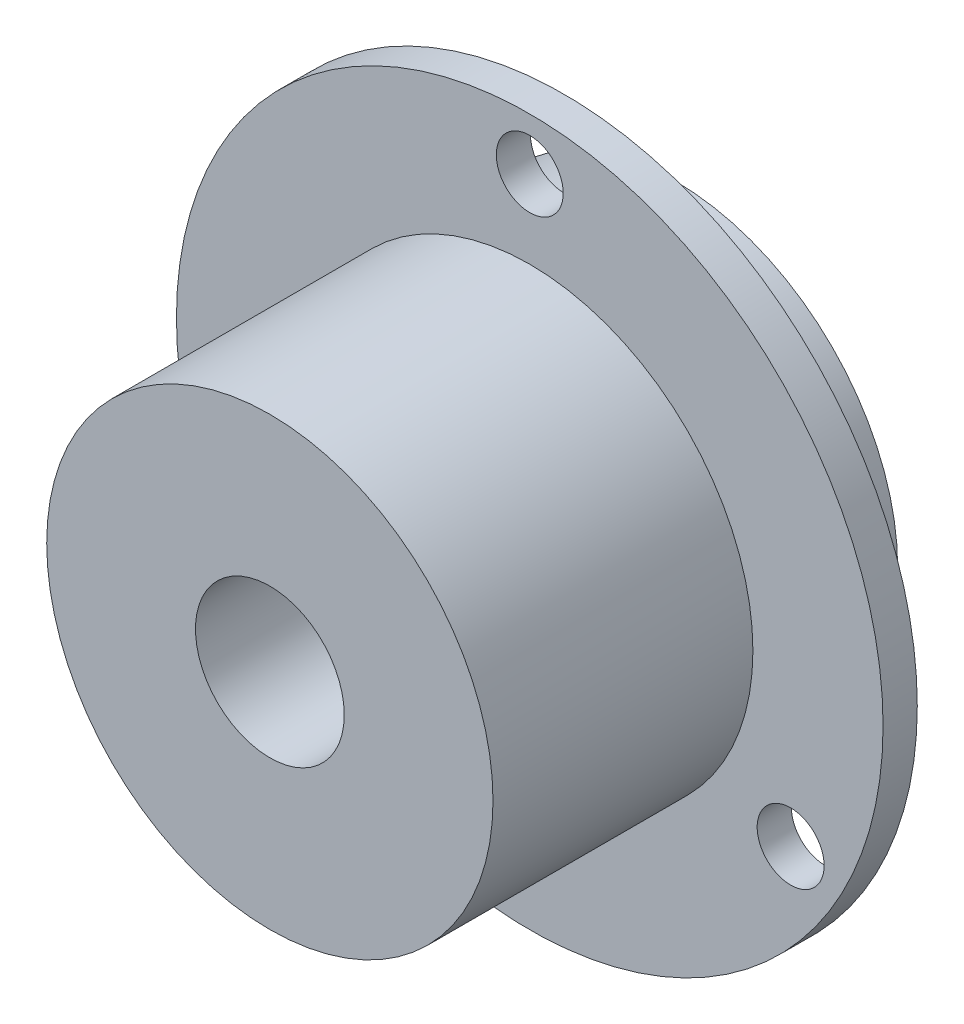
from build123d import *

# Parameters (mm, degrees)
SKETCH3_R          = 2.25
CUT_EXTRUDE1_DEPTH = 5


with BuildPart() as part:
    # Sketch2 → Revolve1 (revolve)
    with BuildSketch(Plane(origin=(0, 0, 0), x_dir=(1, 0, 0), z_dir=(0, 1, 0))):
        Polygon((5, -17.47), (5, 9.73), (15, 9.73), (15, 2.3), (23.75, 2.3), (23.75, 0), (15, 0), (15, -17.47), align=None)
    revolve(axis=Axis((0, 0, 39.284955752), (0, 0, -1)))

    # Sketch3 → Cut-Extrude1 (cut, symmetric)
    with BuildSketch(Plane.XY):
        with Locations((0, 20.25)):
            Circle(SKETCH3_R)
        with Locations((17.537014427, -10.125)):
            Circle(SKETCH3_R)
        with Locations((-17.537014427, -10.125)):
            Circle(SKETCH3_R)
    extrude(amount=CUT_EXTRUDE1_DEPTH, both=True, mode=Mode.SUBTRACT)


solid = part.part
